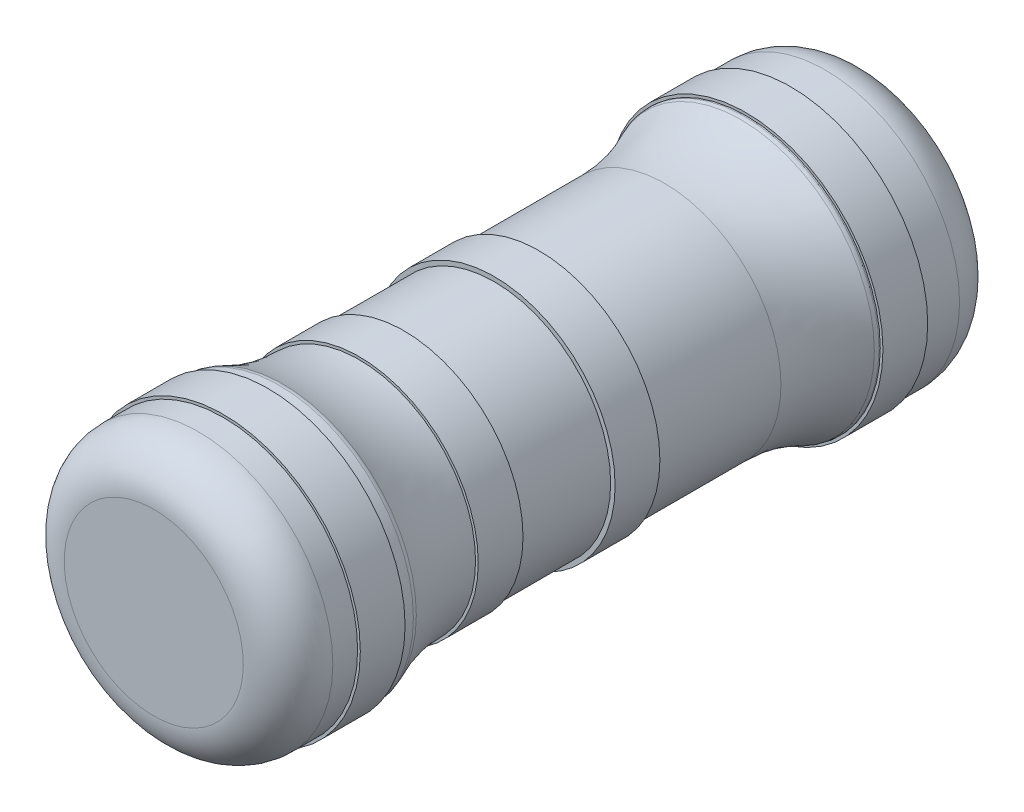
from build123d import *

# Parameters (mm, degrees)
FILLET1_R = 2
SKETCH2_W = 0.5
SKETCH2_H = 0.029991608
SKETCH3_W = 0.5
SKETCH3_H = 0.05
SKETCH4_W = 0.5
SKETCH4_H = 0.03
SKETCH5_W = 0.5
SKETCH5_H = 0.03


with BuildPart() as part:
    # Sketch1 → Revolve1 (revolve)
    with BuildSketch(Plane(origin=(0, 0, 0), x_dir=(0, 0, -1), z_dir=(1, 0, 0))):
        with BuildLine():
            Line((2.6, 1.5), (3.5, 1.5))
            ThreePointArc((3.5, 1.5), (3.853553391, 1.353553391), (4, 1))
            Line((4, 1), (4, 0))
            Line((4, 0), (-4, 0))
            Line((-4, 0), (-4, 1))
            ThreePointArc((-4, 1), (-3.853553391, 1.353553391), (-3.5, 1.5))
            Line((-3.5, 1.5), (-2.6, 1.5))
            ThreePointArc((-2.6, 1.5), (-2.529289322, 1.470710678), (-2.5, 1.4))
            Line((-2.5, 1.4), (-2.5, 1.3))
            Line((-2.5, 1.3), (2.5, 1.3))
            Line((2.5, 1.3), (2.5, 1.4))
            ThreePointArc((2.5, 1.4), (2.529289322, 1.470710678), (2.6, 1.5))
        make_face()
    revolve(axis=Axis((0, 0, 30.94688027), (0, 0, -1)))

    # Fillet1
    fillet1_edges = [part.edges().sort_by_distance(p)[0] for p in [
        (0, -1.3, -2.5),
        (0, -1.3, 2.5),
    ]]
    fillet(fillet1_edges, radius=FILLET1_R)

    # Sketch2 → Revolve2 (revolve)
    with BuildSketch(Plane(origin=(0, 0, 0), x_dir=(0, 0, -1), z_dir=(1, 0, 0))):
        with Locations((-1.455572809, 1.314995804)):
            Rectangle(SKETCH2_W, SKETCH2_H)
    revolve(axis=Axis((0, 0, 2.184724067), (0, 0, -1)))

    # Sketch3 → Revolve3 (revolve)
    with BuildSketch(Plane(origin=(0, 0, 0), x_dir=(0, 0, -1), z_dir=(1, 0, 0))):
        with Locations((0.053199548, 1.325)):
            Rectangle(SKETCH3_W, SKETCH3_H)
    revolve(axis=Axis((0, 0, 0.48939527), (0, 0, -1)))

    # Sketch4 → Revolve4 (revolve)
    with BuildSketch(Plane(origin=(0, 0, 0), x_dir=(0, 0, -1), z_dir=(1, 0, 0))):
        with Locations((-2.972757668, 1.515)):
            Rectangle(SKETCH4_W, SKETCH4_H)
    revolve(axis=Axis((0, 0, 0.449237838), (0, 0, -1)))

    # Sketch5 → Revolve5 (revolve)
    with BuildSketch(Plane(origin=(0, 0, 0), x_dir=(0, 0, -1), z_dir=(1, 0, 0))):
        with Locations((2.864549609, 1.515)):
            Rectangle(SKETCH5_W, SKETCH5_H)
    revolve(axis=Axis((0, 0, 0.313399994), (0, 0, -1)))


solid = part.part
